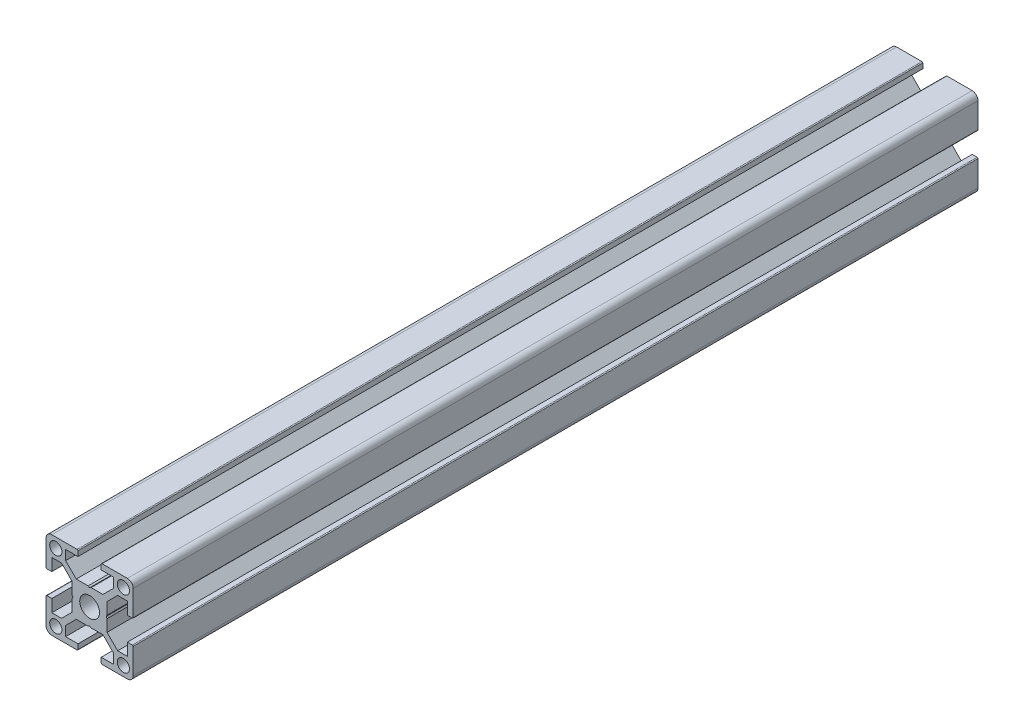
from build123d import *

# Parameters (mm, degrees)
SKETCH_1_R      = 1.4
SKETCH_1_R_2    = 2.266666667
EXTRUDE_1_DEPTH = 193.8


with BuildPart() as part:
    # 草图1 → 凸台-拉伸1 (new body)
    with BuildSketch(Plane.XY):
        with BuildLine():
            Line((5, 23.666666667), (5, 17.866666667))
            ThreePointArc((5, 17.866666667), (5.058578644, 17.72524531), (5.2, 17.666666667))
            Line((5.2, 17.666666667), (6.333333333, 17.666666667))
            Line((6.333333333, 17.666666667), (6.333333333, 20.5))
            Line((6.333333333, 20.5), (8.557190958, 20.5))
            Line((8.557190958, 20.5), (11, 18.057190958))
            Line((11, 18.057190958), (11, 15.346410162))
            Line((11, 15.346410162), (11.199999976, 15.000000042))
            Line((11.199999976, 15.000000042), (11, 14.653589838))
            Line((11, 14.653589838), (11, 11.942809042))
            Line((11, 11.942809042), (8.557190958, 9.5))
            Line((8.557190958, 9.5), (6.333333333, 9.5))
            Line((6.333333333, 9.5), (6.333333333, 12.333333333))
            Line((6.333333333, 12.333333333), (5.2, 12.333333333))
            ThreePointArc((5.2, 12.333333333), (5.058578644, 12.27475469), (5, 12.133333333))
            Line((5, 12.133333333), (5, 6.333333333))
            ThreePointArc((5, 6.333333333), (5.390524292, 5.390524292), (6.333333333, 5))
            Line((6.333333333, 5), (12.133333333, 5))
            ThreePointArc((12.133333333, 5), (12.27475469, 5.058578644), (12.333333333, 5.2))
            Line((12.333333333, 5.2), (12.333333333, 6.333333333))
            Line((12.333333333, 6.333333333), (9.5, 6.333333333))
            Line((9.5, 6.333333333), (9.5, 8.557190958))
            Line((9.5, 8.557190958), (11.942809042, 11))
            Line((11.942809042, 11), (14.653589838, 11))
            Line((14.653589838, 11), (14.999999928, 11.199999958))
            Line((14.999999928, 11.199999958), (15.346410162, 11))
            Line((15.346410162, 11), (18.057190958, 11))
            Line((18.057190958, 11), (20.5, 8.557190958))
            Line((20.5, 8.557190958), (20.5, 6.333333333))
            Line((20.5, 6.333333333), (17.666666667, 6.333333333))
            Line((17.666666667, 6.333333333), (17.666666667, 5.2))
            ThreePointArc((17.666666667, 5.2), (17.72524531, 5.058578644), (17.866666667, 5))
            Line((17.866666667, 5), (23.666666667, 5))
            ThreePointArc((23.666666667, 5), (24.609475708, 5.390524292), (25, 6.333333333))
            Line((25, 6.333333333), (25, 12.133333333))
            ThreePointArc((25, 12.133333333), (24.941421356, 12.27475469), (24.8, 12.333333333))
            Line((24.8, 12.333333333), (23.666666667, 12.333333333))
            Line((23.666666667, 12.333333333), (23.666666667, 9.5))
            Line((23.666666667, 9.5), (21.442809042, 9.5))
            Line((21.442809042, 9.5), (19, 11.942809042))
            Line((19, 11.942809042), (19, 14.653589838))
            Line((19, 14.653589838), (18.800000024, 14.999999958))
            Line((18.800000024, 14.999999958), (19, 15.346410162))
            Line((19, 15.346410162), (19, 18.057190958))
            Line((19, 18.057190958), (21.442809042, 20.5))
            Line((21.442809042, 20.5), (23.666666667, 20.5))
            Line((23.666666667, 20.5), (23.666666667, 17.666666667))
            Line((23.666666667, 17.666666667), (24.8, 17.666666667))
            ThreePointArc((24.8, 17.666666667), (24.941421356, 17.72524531), (25, 17.866666667))
            Line((25, 17.866666667), (25, 23.666666667))
            ThreePointArc((25, 23.666666667), (24.609475708, 24.609475708), (23.666666667, 25))
            Line((23.666666667, 25), (17.866666667, 25))
            ThreePointArc((17.866666667, 25), (17.72524531, 24.941421356), (17.666666667, 24.8))
            Line((17.666666667, 24.8), (17.666666667, 23.666666667))
            Line((17.666666667, 23.666666667), (20.5, 23.666666667))
            Line((20.5, 23.666666667), (20.5, 21.442809042))
            Line((20.5, 21.442809042), (18.057190958, 19))
            Line((18.057190958, 19), (15.346410162, 19))
            Line((15.346410162, 19), (15.000000072, 18.800000042))
            Line((15.000000072, 18.800000042), (14.653589838, 19))
            Line((14.653589838, 19), (11.942809042, 19))
            Line((11.942809042, 19), (9.5, 21.442809042))
            Line((9.5, 21.442809042), (9.5, 23.666666667))
            Line((9.5, 23.666666667), (12.333333333, 23.666666667))
            Line((12.333333333, 23.666666667), (12.333333333, 24.8))
            ThreePointArc((12.333333333, 24.8), (12.27475469, 24.941421356), (12.133333333, 25))
            Line((12.133333333, 25), (6.333333333, 25))
            ThreePointArc((6.333333333, 25), (5.390524292, 24.609475708), (5, 23.666666667))
        make_face()
        with Locations((7.25, 22.75)):
            Circle(SKETCH_1_R, mode=Mode.SUBTRACT)
        with Locations((22.75, 22.75)):
            Circle(SKETCH_1_R, mode=Mode.SUBTRACT)
        with Locations((15, 15)):
            Circle(SKETCH_1_R_2, mode=Mode.SUBTRACT)
        with Locations((7.25, 7.25)):
            Circle(SKETCH_1_R, mode=Mode.SUBTRACT)
        with Locations((22.75, 7.25)):
            Circle(SKETCH_1_R, mode=Mode.SUBTRACT)
    extrude(amount=EXTRUDE_1_DEPTH)


solid = part.part
